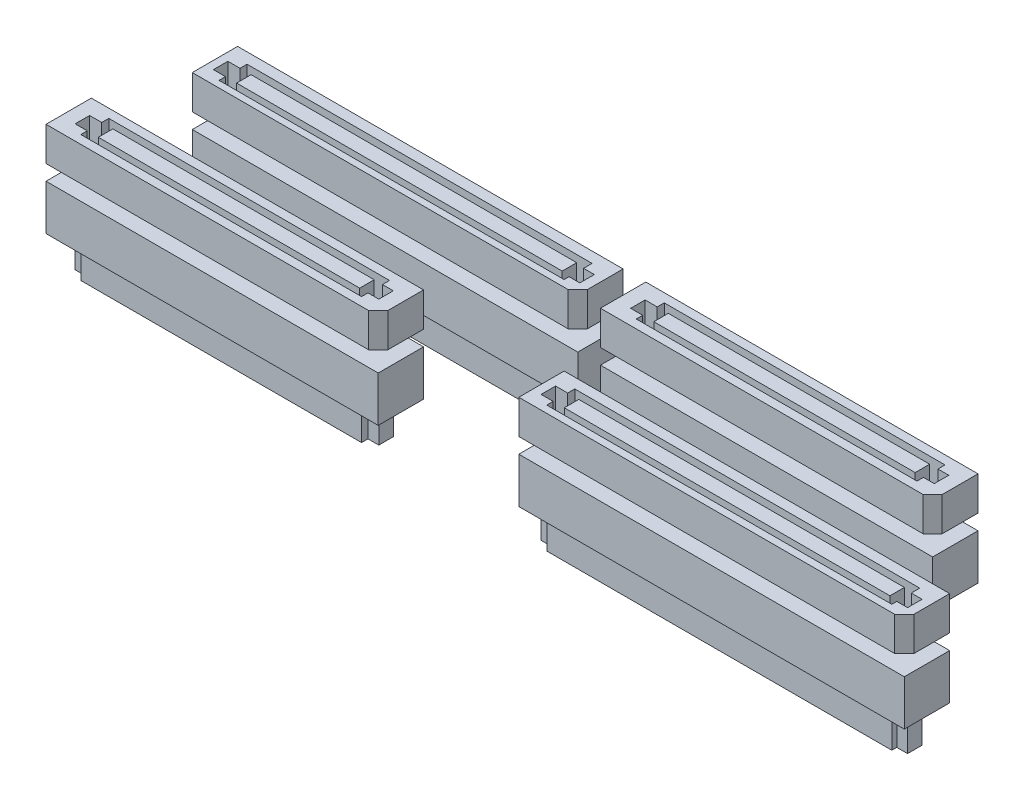
from build123d import *

# Parameters (mm, degrees)
SV_DEPTH           = 3.75
SV_2_DEPTH         = 3.75
SV_3_DEPTH         = 3.75
SV_4_DEPTH         = 3.75
SKETCH3_W          = 28.811718275
SKETCH3_H          = 1.597828601
SKETCH3_W_2        = 35.897762959
SKETCH3_W_3        = 35.897762958
CUT_EXTRUDE1_DEPTH = 3.5
SV4_A_DEPTH        = 5
SV4_A_2_DEPTH      = 5
SV4_A_3_DEPTH      = 5
SV4_A_4_DEPTH      = 5
SKETCH7_W          = 35.897762958
SKETCH7_H          = 1.597828601
SKETCH7_W_2        = 28.811718275
SKETCH7_W_3        = 35.897762959
SV4_B_DEPTH        = 3.5


with BuildPart() as part:
    # Sketch1 → SV (new body)
    with BuildSketch(Plane(origin=(0, 0, 0), x_dir=(1, 0, 0), z_dir=(0, 1, 0))):
        Polygon((55.811, 9.5), (97.25, 9.5), (97.25, 5.56), (96.19, 4.5), (54.75, 4.5), (54.75, 8.439), (54.75, 9.5), align=None)
    extrude(amount=SV_DEPTH)


with BuildPart() as body_2:
    # Sketch1 → SV 2 (new body)
    with BuildSketch(Plane(origin=(0, 0, 0), x_dir=(1, 0, 0), z_dir=(0, 1, 0))):
        Polygon((3.686, 9.5), (39.25, 9.5), (39.25, 5.555), (38.195, 4.5), (2.625, 4.5), (2.625, 8.439), (2.625, 9.5), align=None)
    extrude(amount=SV_2_DEPTH)


with BuildPart() as body_3:
    # Sketch1 → SV 3 (new body)
    with BuildSketch(Plane(origin=(0, 0, 0), x_dir=(1, 0, 0), z_dir=(0, 1, 0))):
        Polygon((51.811, 22.5), (87.375, 22.5), (87.375, 18.555), (86.32, 17.5), (50.75, 17.5), (50.75, 21.439), (50.75, 22.5), align=None)
    extrude(amount=SV_3_DEPTH)


with BuildPart() as body_4:
    # Sketch1 → SV 4 (new body)
    with BuildSketch(Plane(origin=(0, 0, 0), x_dir=(1, 0, 0), z_dir=(0, 1, 0))):
        Polygon((6.811, 22.5), (48.25, 22.5), (48.25, 18.56), (47.19, 17.5), (5.75, 17.5), (5.75, 21.439), (5.75, 22.5), align=None)
    extrude(amount=SV_4_DEPTH)


with BuildPart() as cut_extrude1_tool:
    # Sketch3 → Cut-Extrude1 (new body)
    with BuildSketch(Plane(origin=(0, 3.75, 0), x_dir=(1, 0, 0), z_dir=(0, 1, 0))):
        Polygon((4.189336253, 7.745735487), (5.524337048, 7.745735487), (5.524337048, 8.524173538), (36.475691419, 8.524173538), (36.475691419, 7.745735487), (37.666991912, 7.745735487), (37.666991912, 6.147906886), (36.475691419, 6.147906886), (36.475691419, 5.438560322), (5.524337048, 5.438560322), (5.524337048, 6.147906886), (4.189336253, 6.147906886), align=None)
        with Locations((21.152985591, 6.946821187)):
            Rectangle(SKETCH3_W, SKETCH3_H, mode=Mode.SUBTRACT)
        Polygon((52.421116037, 20.753597434), (53.756116831, 20.753597434), (53.756116831, 21.532035485), (84.707471203, 21.532035485), (84.707471203, 20.753597434), (85.898771695, 20.753597434), (85.898771695, 19.155768833), (84.707471203, 19.155768833), (84.707471203, 18.446422269), (53.756116831, 18.446422269), (53.756116831, 19.155768833), (52.421116037, 19.155768833), align=None)
        with Locations((69.384765375, 19.954683133)):
            Rectangle(SKETCH3_W, SKETCH3_H, mode=Mode.SUBTRACT)
        Polygon((55.705906871, 7.599031898), (57.040907666, 7.599031898), (57.040907666, 8.377469948), (95.07830672, 8.377469948), (95.07830672, 7.437727621), (96.269607213, 7.437727621), (96.269607213, 5.83989902), (95.07830672, 5.83989902), (95.07830672, 5.291856733), (57.040907666, 5.291856733), (57.040907666, 6.001203297), (55.705906871, 6.001203297), align=None)
        with Locations((76.21257855, 6.800117597)):
            Rectangle(SKETCH3_W_2, SKETCH3_H, mode=Mode.SUBTRACT)
        Polygon((6.636601859, 20.53972103), (7.971602653, 20.53972103), (7.971602653, 21.318159081), (46.009001708, 21.318159081), (46.009001708, 20.378416754), (47.2003022, 20.378416754), (47.2003022, 18.780588153), (46.009001708, 18.780588153), (46.009001708, 18.232545866), (7.971602653, 18.232545866), (7.971602653, 18.941892429), (6.636601859, 18.941892429), align=None)
        with Locations((27.143273538, 19.74080673)):
            Rectangle(SKETCH3_W_3, SKETCH3_H, mode=Mode.SUBTRACT)
    extrude(amount=-CUT_EXTRUDE1_DEPTH)


with BuildPart() as part_1:
    add(part.part)

    # Cut-Extrude1: cut by cut_extrude1_tool
    add(cut_extrude1_tool.part, mode=Mode.SUBTRACT)


with BuildPart() as body_2_1:
    add(body_2.part)

    # Cut-Extrude1: cut by cut_extrude1_tool
    add(cut_extrude1_tool.part, mode=Mode.SUBTRACT)


with BuildPart() as body_3_1:
    add(body_3.part)

    # Cut-Extrude1: cut by cut_extrude1_tool
    add(cut_extrude1_tool.part, mode=Mode.SUBTRACT)


with BuildPart() as body_4_1:
    add(body_4.part)

    # Cut-Extrude1: cut by cut_extrude1_tool
    add(cut_extrude1_tool.part, mode=Mode.SUBTRACT)


with BuildPart() as body_5:
    # Sketch6 → SV4(a) (new body)
    with BuildSketch(Plane(origin=(0, -1.68656, 0), x_dir=(1, 0, 0), z_dir=(0, 1, 0))):
        Polygon((2.625, 4.5), (38.195, 4.5), (39.25, 4.5), (39.25, 5.555), (39.25, 9.5), (3.685, 9.5), (2.625, 8.44), align=None)
    extrude(amount=-SV4_A_DEPTH)



with BuildPart() as body_6:
    # Sketch6 → SV4_a 2 (new body)
    with BuildSketch(Plane(origin=(0, -1.68656, 0), x_dir=(1, 0, 0), z_dir=(0, 1, 0))):
        Polygon((48.25, 18.56191605), (48.25, 22.5), (6.81, 22.5), (5.75, 21.44), (5.75, 17.5), (47.18808395, 17.5), (48.25, 17.5), align=None)
    extrude(amount=-SV4_A_2_DEPTH)


with BuildPart() as body_7:
    # Sketch6 → SV4_a 3 (new body)
    with BuildSketch(Plane(origin=(0, -1.68656, 0), x_dir=(1, 0, 0), z_dir=(0, 1, 0))):
        Polygon((54.75, 4.5), (96.19, 4.5), (97.25, 4.5), (97.25, 5.56), (97.25, 9.5), (55.81, 9.5), (54.75, 8.44), align=None)
    extrude(amount=-SV4_A_3_DEPTH)


with BuildPart() as body_8:
    # Sketch6 → SV4_a 4 (new body)
    with BuildSketch(Plane(origin=(0, -1.68656, 0), x_dir=(1, 0, 0), z_dir=(0, 1, 0))):
        Polygon((50.75, 17.5), (86.32, 17.5), (87.375, 17.5), (87.375, 18.555), (87.375, 22.5), (51.805, 22.5), (50.75, 21.445), align=None)
    extrude(amount=-SV4_A_4_DEPTH)


with BuildPart() as body_5_1:
    add(body_5.part)

    add(body_6.part)  # SV4(b) merges body 6

    add(body_7.part)  # SV4(b) merges body 7

    add(body_8.part)  # SV4(b) merges body 8
    # Sketch7 → SV4(b) (add)
    with BuildSketch(Plane.XZ.offset(6.68656)):
        Polygon((7.971602653, -21.318159081), (7.971602653, -20.53972103), (6.636601859, -20.53972103), (6.636601859, -18.941892429), (7.971602653, -18.941892429), (7.971602653, -18.232545866), (46.009001708, -18.232545866), (46.009001708, -18.780588153), (47.2003022, -18.780588153), (47.2003022, -20.378416754), (46.009001708, -20.378416754), (46.009001708, -21.318159081), align=None)
        with Locations((27.143273538, -19.74080673)):
            Rectangle(SKETCH7_W, SKETCH7_H, mode=Mode.SUBTRACT)
        Polygon((53.756116831, -21.532035485), (84.707471203, -21.532035485), (84.707471203, -20.753597434), (85.898771695, -20.753597434), (85.898771695, -19.155768833), (84.707471203, -19.155768833), (84.707471203, -18.446422269), (53.756116831, -18.446422269), (53.756116831, -19.155768833), (52.421116037, -19.155768833), (52.421116037, -20.753597434), (53.756116831, -20.753597434), align=None)
        with Locations((69.384765375, -19.954683133)):
            Rectangle(SKETCH7_W_2, SKETCH7_H, mode=Mode.SUBTRACT)
        Polygon((57.040907666, -8.377469948), (57.040907666, -7.599031898), (55.705906871, -7.599031898), (55.705906871, -6.001203297), (57.040907666, -6.001203297), (57.040907666, -5.291856733), (95.07830672, -5.291856733), (95.07830672, -5.83989902), (96.269607213, -5.83989902), (96.269607213, -7.437727621), (95.07830672, -7.437727621), (95.07830672, -8.377469948), align=None)
        with Locations((76.21257855, -6.800117597)):
            Rectangle(SKETCH7_W_3, SKETCH7_H, mode=Mode.SUBTRACT)
        Polygon((4.189336253, -6.147906886), (5.524337048, -6.147906886), (5.524337048, -5.438560322), (36.475691419, -5.438560322), (36.475691419, -6.147906886), (37.666991912, -6.147906886), (37.666991912, -7.745735487), (36.475691419, -7.745735487), (36.475691419, -8.524173538), (5.524337048, -8.524173538), (5.524337048, -7.745735487), (4.189336253, -7.745735487), align=None)
        with Locations((21.152985591, -6.946821187)):
            Rectangle(SKETCH7_W_2, SKETCH7_H, mode=Mode.SUBTRACT)
    extrude(amount=SV4_B_DEPTH)


solid = Compound([part_1.part, body_2_1.part, body_3_1.part, body_4_1.part, body_5_1.part])
